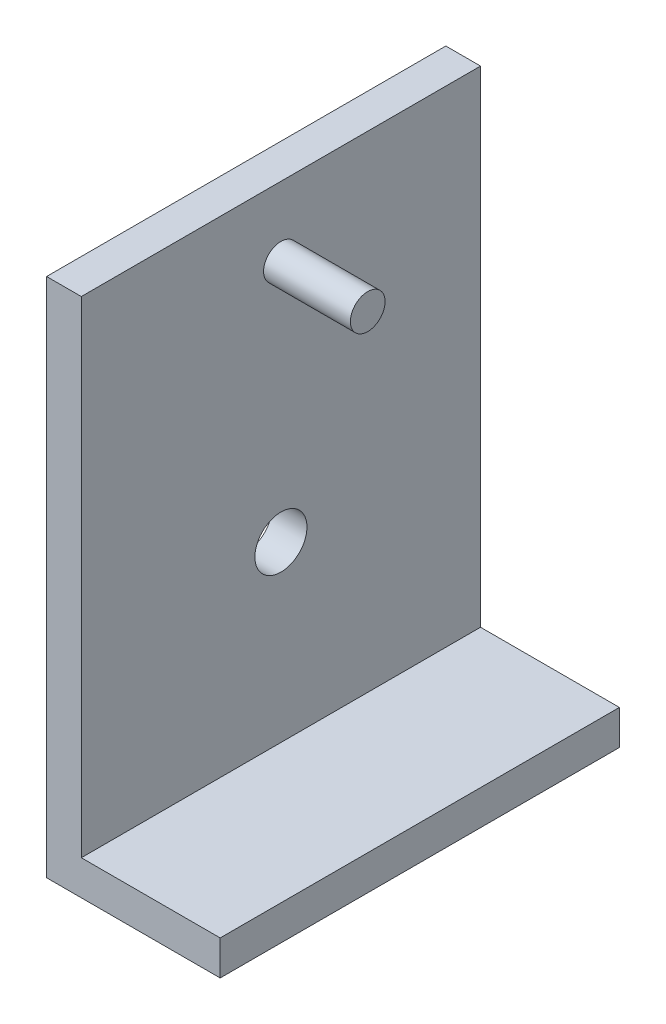
from build123d import *

# Parameters (mm, degrees)
BOSS_EXTRUDE1_DEPTH = 57.5
SKETCH2_R           = 7.5
CUT_EXTRUDE1_DEPTH  = 51
SKETCH3_R           = 5
BOSS_EXTRUDE2_DEPTH = 25


with BuildPart() as part:
    # Sketch1 → Boss-Extrude1 (new body, symmetric)
    with BuildSketch(Plane.XY):
        Polygon((0, 150), (0, 0), (50, 0), (50, 10), (10, 10), (10, 150), align=None)
    extrude(amount=BOSS_EXTRUDE1_DEPTH, both=True)

    # Sketch2 → Cut-Extrude1 (cut, through all)
    with BuildSketch(Plane.ZY):
        with Locations((0, 60)):
            Circle(SKETCH2_R)
    extrude(amount=-CUT_EXTRUDE1_DEPTH, mode=Mode.SUBTRACT)

    # Sketch3 → Boss-Extrude2 (add)
    with BuildSketch(Plane(origin=(10, 0, 0), x_dir=(0, 0, -1), z_dir=(1, 0, 0))):
        with Locations((0, 130)):
            Circle(SKETCH3_R)
    extrude(amount=BOSS_EXTRUDE2_DEPTH)


solid = part.part
